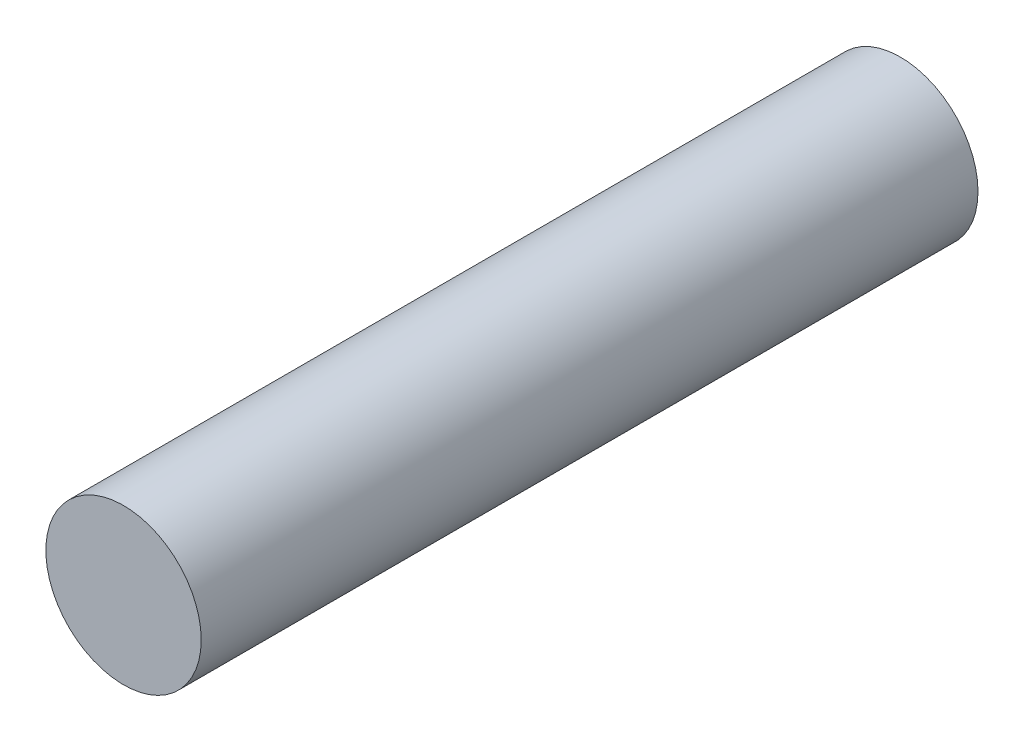
from build123d import *

# Parameters (mm, degrees)
SKETCH1_R           = 1.27
BOSS_EXTRUDE1_DEPTH = 12.7


with BuildPart() as part:
    # Sketch1 → Boss-Extrude1 (new body)
    with BuildSketch(Plane.XY):
        Circle(SKETCH1_R)
    extrude(amount=BOSS_EXTRUDE1_DEPTH)


solid = part.part
